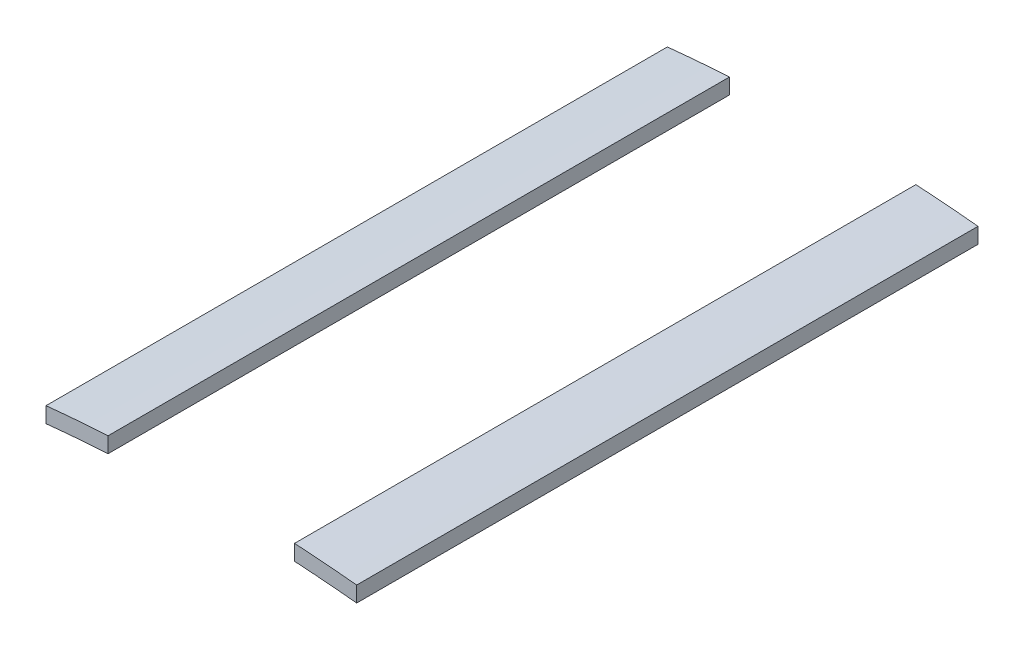
from build123d import *

# Parameters (mm, degrees)
BOSS_EXTRUDE4_DEPTH   = 20
BOSS_EXTRUDE4_2_DEPTH = 20


with BuildPart() as part:
    # Sketch4 → Boss-Extrude4 (new body)
    with BuildSketch(Plane.XY):
        with BuildLine():
            Line((5, 49.246827309), (5, 48.744230428))
            ThreePointArc((5, 48.744230428), (4.000838841, 48.836393075), (3, 48.908077043))
            Line((3, 48.908077043), (3, 49.409007276))
            ThreePointArc((3, 49.409007276), (4.000821864, 49.338052499), (5, 49.246827309))
        make_face()
    extrude(amount=BOSS_EXTRUDE4_DEPTH)


with BuildPart() as body_2:
    # Sketch4 → Boss-Extrude4 2 (new body)
    with BuildSketch(Plane.XY):
        with BuildLine():
            Line((-3, 49.409007276), (-3, 48.908077043))
            ThreePointArc((-3, 48.908077043), (-4.000838841, 48.836393075), (-5, 48.744230428))
            Line((-5, 48.744230428), (-5, 49.246827309))
            ThreePointArc((-5, 49.246827309), (-4.000821864, 49.338052499), (-3, 49.409007276))
        make_face()
    extrude(amount=BOSS_EXTRUDE4_2_DEPTH)


solid = Compound([part.part, body_2.part])
